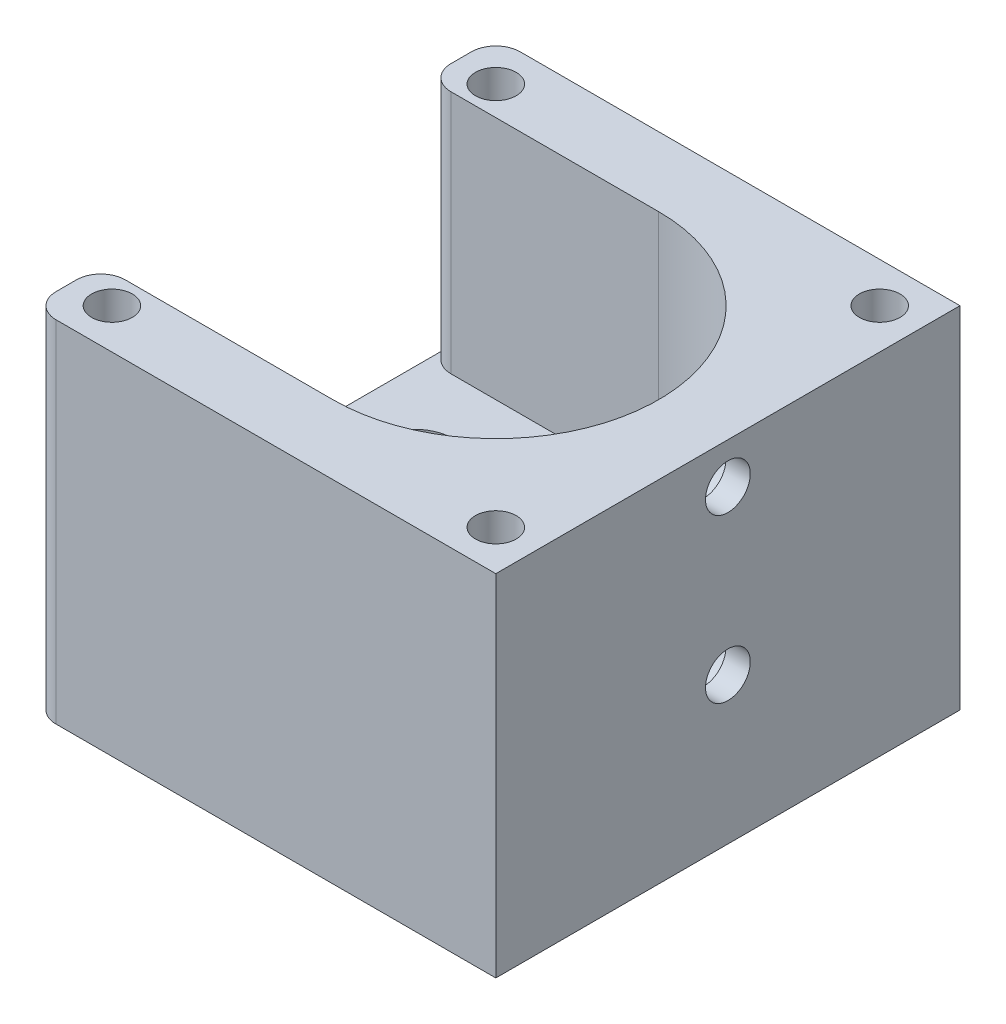
from build123d import *

# Parameters (mm, degrees)
SKETCH1_W           = 57
SKETCH1_H           = 57
BOSS_EXTRUDE1_DEPTH = 13
BOSS_EXTRUDE2_DEPTH = 30
SKETCH3_R           = 2.75
CUT_EXTRUDE1_DEPTH  = 57
SKETCH4_R           = 4.75
CUT_EXTRUDE6_DEPTH  = 54
SKETCH5_R           = 2.5
CUT_EXTRUDE7_DEPTH  = 5
SKETCH6_R           = 2.75
CUT_EXTRUDE8_DEPTH  = 14
SKETCH7_R           = 4.75
CUT_EXTRUDE9_DEPTH  = 5
FILLET1_R           = 3


with BuildPart() as part:
    # Sketch1 → Boss-Extrude1 (new body)
    with BuildSketch(Plane(origin=(0, 0, 0), x_dir=(1, 0, 0), z_dir=(0, 1, 0))):
        Rectangle(SKETCH1_W, SKETCH1_H)
    extrude(amount=BOSS_EXTRUDE1_DEPTH)

    # Sketch2 → Boss-Extrude2 (add)
    with BuildSketch(Plane(origin=(0, 13, 0), x_dir=(1, 0, 0), z_dir=(0, 1, 0))):
        with BuildLine():
            Line((0, 20), (-28.5, 20))
            Line((-28.5, 20), (-28.5, 28.5))
            Line((-28.5, 28.5), (28.5, 28.5))
            Line((28.5, 28.5), (28.5, -28.5))
            Line((28.5, -28.5), (-28.5, -28.5))
            Line((-28.5, -28.5), (-28.5, -20))
            Line((-28.5, -20), (0, -20))
            ThreePointArc((0, -20), (20, 0), (0, 20))
        make_face()
    extrude(amount=BOSS_EXTRUDE2_DEPTH)

    # Sketch3 → Cut-Extrude1 (cut)
    with BuildSketch(Plane.ZY.offset(28.5)):
        with Locations((0, 18)):
            Circle(SKETCH3_R)
        with Locations((0, 38)):
            Circle(SKETCH3_R)
    extrude(amount=-CUT_EXTRUDE1_DEPTH, mode=Mode.SUBTRACT)

    # Sketch4 → Cut-Extrude6 (cut)
    with BuildSketch(Plane.ZY.offset(28.5)):
        with Locations((0, 38)):
            Circle(SKETCH4_R)
        with Locations((0, 18)):
            Circle(SKETCH4_R)
    extrude(amount=-CUT_EXTRUDE6_DEPTH, mode=Mode.SUBTRACT)

    # Sketch5 → Cut-Extrude7 (cut)
    with BuildSketch(Plane(origin=(0, 43, 0), x_dir=(1, 0, 0), z_dir=(0, 1, 0))):
        with Locations((-23.57, 23.57)):
            Circle(SKETCH5_R)
        with Locations((23.57, 23.57)):
            Circle(SKETCH5_R)
        with Locations((23.57, -23.57)):
            Circle(SKETCH5_R)
        with Locations((-23.57, -23.57)):
            Circle(SKETCH5_R)
    extrude(amount=-CUT_EXTRUDE7_DEPTH, mode=Mode.SUBTRACT)

    # Sketch6 → Cut-Extrude8 (cut, through all)
    with BuildSketch(Plane(origin=(0, 13, 0), x_dir=(1, 0, 0), z_dir=(0, 1, 0))):
        with Locations((-18.5, 8.5)):
            Circle(SKETCH6_R)
        with Locations((8.5, 8.5)):
            Circle(SKETCH6_R)
    extrude(amount=-CUT_EXTRUDE8_DEPTH, mode=Mode.SUBTRACT)

    # Sketch7 → Cut-Extrude9 (cut)
    with BuildSketch(Plane(origin=(0, 13, 0), x_dir=(1, 0, 0), z_dir=(0, 1, 0))):
        with Locations((-18.5, 8.5)):
            Circle(SKETCH7_R)
        with Locations((8.5, 8.5)):
            Circle(SKETCH7_R)
    extrude(amount=-CUT_EXTRUDE9_DEPTH, mode=Mode.SUBTRACT)

    # Fillet1
    fillet1_edges = [part.edges().sort_by_distance(p)[0] for p in [
        (-28.5, 28, -20),
        (-28.5, 28, 20),
        (-28.5, 21.5, -28.5),
        (-28.5, 21.5, 28.5),
    ]]
    fillet(fillet1_edges, radius=FILLET1_R)


solid = part.part
